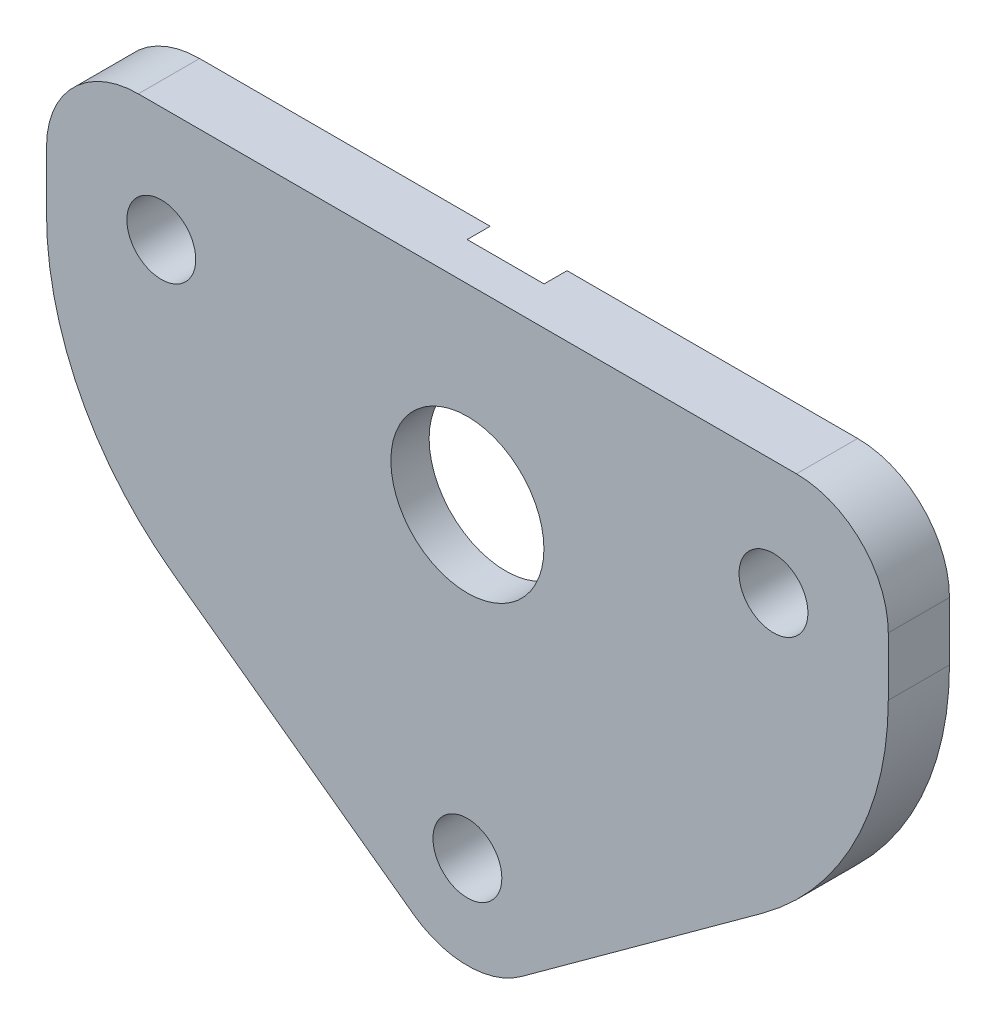
from build123d import *

# Parameters (mm, degrees)
ESQUISSE1_R              = 5
ESQUISSE1_R_2            = 2.25
BOSS_EXTRU_1_DEPTH       = 4
CONG_2_R                 = 6
CONG_3_R                 = 20
ESQUISSE4_R              = 12.75
ENL_V_MAT_EXTRU_20_DEPTH = 1.5


with BuildPart() as part:
    # Esquisse1 → Boss.-Extru.1 (new body)
    with BuildSketch(Plane.XY):
        Polygon((-55, 20), (-27.5, 0), (0, 20), (0, 40), (-55, 40), align=None)
        with Locations((-27.5, 27.5)):
            Circle(ESQUISSE1_R, mode=Mode.SUBTRACT)
        with Locations((-47.5, 32.5)):
            Circle(ESQUISSE1_R_2, mode=Mode.SUBTRACT)
        with Locations((-7.5, 32.5)):
            Circle(ESQUISSE1_R_2, mode=Mode.SUBTRACT)
        with Locations((-27.5, 7.5)):
            Circle(ESQUISSE1_R_2, mode=Mode.SUBTRACT)
    extrude(amount=BOSS_EXTRU_1_DEPTH)

    # Congé2
    cong_2_edges = [part.edges().sort_by_distance(p)[0] for p in [
        (-55, 40, 2),
        (0, 40, 2),
        (-27.5, 0, 2),
    ]]
    fillet(cong_2_edges, radius=CONG_2_R)

    # Congé3
    cong_3_edges = [part.edges().sort_by_distance(p)[0] for p in [
        (0, 20, 2),
        (-55, 20, 2),
    ]]
    fillet(cong_3_edges, radius=CONG_3_R)

    # Esquisse4 → Enlèv. mat.-Extru.20 (cut)
    with BuildSketch(Plane(origin=(0, 0, 0), x_dir=(-1, 0, 0), z_dir=(0, 0, -1))):
        with Locations((27.5, 27.5)):
            Circle(ESQUISSE4_R)
    extrude(amount=-ENL_V_MAT_EXTRU_20_DEPTH, mode=Mode.SUBTRACT)


solid = part.part
